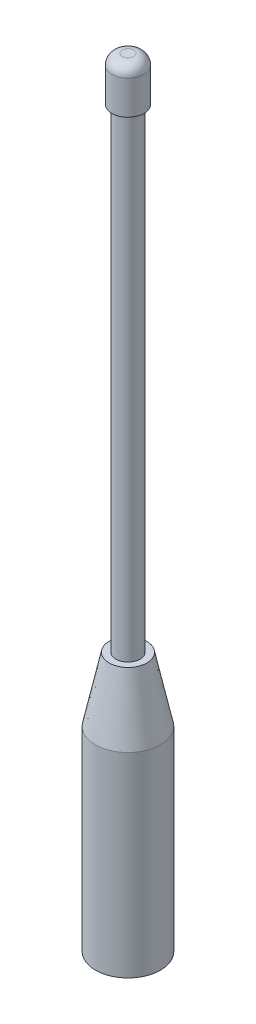
from build123d import *

# Parameters (mm, degrees)
SKETCH1_R           = 2.38125
BOSS_EXTRUDE1_DEPTH = 152.4
SKETCH2_R           = 6.35
BOSS_EXTRUDE2_DEPTH = 50.8
CHAMFER1_SIZE       = 12.54
CHAMFER1_SIZE2      = 2.665459283
SKETCH3_R           = 3.14325
BOSS_EXTRUDE3_DEPTH = 8.636
FILLET1_R           = 2.032


with BuildPart() as part:
    # Sketch1 → Boss-Extrude1 (new body)
    with BuildSketch(Plane(origin=(0, 0, 0), x_dir=(1, 0, 0), z_dir=(0, 1, 0))):
        Circle(SKETCH1_R)
    extrude(amount=BOSS_EXTRUDE1_DEPTH)

    # Sketch2 → Boss-Extrude2 (add)
    with BuildSketch(Plane(origin=(0, 0, 0), x_dir=(1, 0, 0), z_dir=(0, 1, 0))):
        Circle(SKETCH2_R)
    extrude(amount=BOSS_EXTRUDE2_DEPTH)

    # Chamfer1
    chamfer1_edges = [part.edges().sort_by_distance(p)[0] for p in [
        (-6.35, 50.8, 0),
    ]]
    chamfer1_side = [part.faces().sort_by_distance(p)[0] for p in [
        (-6.35, 25.4, 0),
    ]]
    chamfer(chamfer1_edges, length=CHAMFER1_SIZE, length2=CHAMFER1_SIZE2, reference=chamfer1_side[0])

    # Sketch3 → Boss-Extrude3 (add)
    with BuildSketch(Plane(origin=(0, 152.4, 0), x_dir=(1, 0, 0), z_dir=(0, 1, 0))):
        Circle(SKETCH3_R)
    extrude(amount=-BOSS_EXTRUDE3_DEPTH)

    # Fillet1
    fillet1_edges = [part.edges().sort_by_distance(p)[0] for p in [
        (-3.14325, 152.4, 0),
    ]]
    fillet(fillet1_edges, radius=FILLET1_R)


solid = part.part
